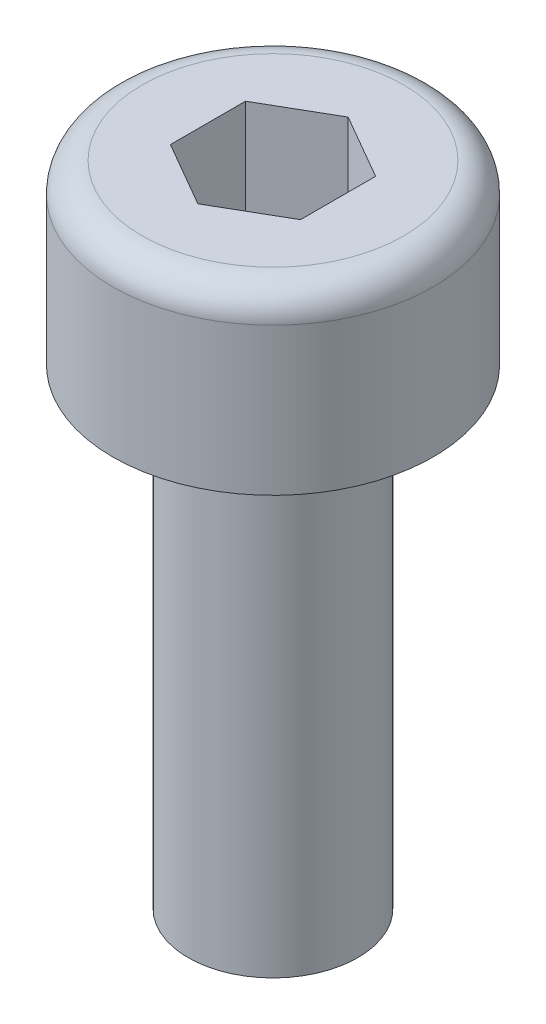
from build123d import *

# Parameters (mm, degrees)
SKETCH1_R           = 2.72
BOSS_EXTRUDE1_DEPTH = 3
SKETCH2_R           = 1.44
BOSS_EXTRUDE2_DEPTH = 8
CUT_EXTRUDE1_DEPTH  = 1.95
FILLET1_R           = 0.5


with BuildPart() as part:
    # Sketch1 → Boss-Extrude1 (new body)
    with BuildSketch(Plane(origin=(0, 0, 0), x_dir=(1, 0, 0), z_dir=(0, 1, 0))):
        Circle(SKETCH1_R)
    extrude(amount=BOSS_EXTRUDE1_DEPTH)

    # Sketch2 → Boss-Extrude2 (add)
    with BuildSketch(Plane.XZ):
        Circle(SKETCH2_R)
    extrude(amount=BOSS_EXTRUDE2_DEPTH)

    # Sketch3 → Cut-Extrude1 (cut)
    with BuildSketch(Plane(origin=(0, 3, 0), x_dir=(1, 0, 0), z_dir=(0, 1, 0))):
        Polygon((1.10418239, 0.6375), (0, 1.275), (-1.10418239, 0.6375), (-1.10418239, -0.6375), (0, -1.275), (1.10418239, -0.6375), align=None)
    extrude(amount=-CUT_EXTRUDE1_DEPTH, mode=Mode.SUBTRACT)

    # Fillet1
    fillet1_edges = [part.edges().sort_by_distance(p)[0] for p in [
        (-2.72, 3, 0),
    ]]
    fillet(fillet1_edges, radius=FILLET1_R)


solid = part.part
